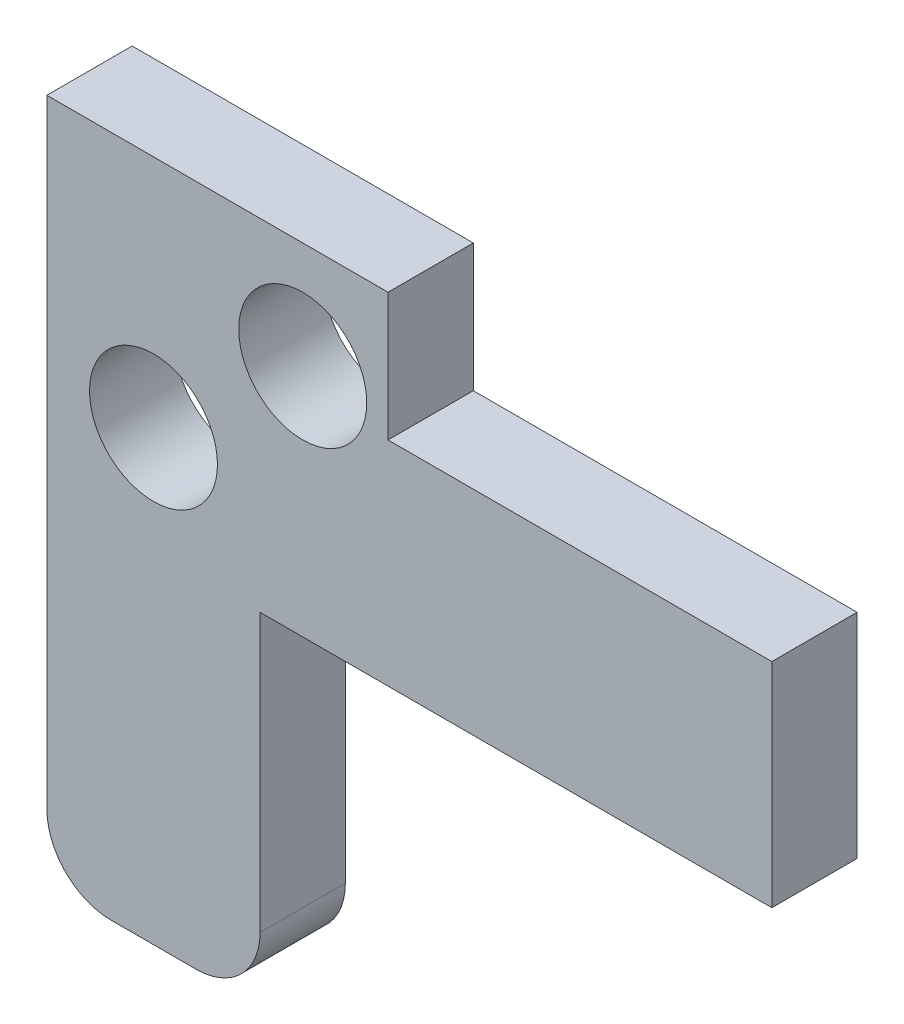
from build123d import *

# Parameters (mm, degrees)
SKETCH_6_W          = 5
SKETCH_6_H          = 21
EXTRUDE_1_DEPTH     = 2
SKETCH_10_W         = 2
SKETCH_10_H         = 5
EXTRUDE_3_DEPTH     = 20
SKETCH_11_W         = 8
SKETCH_11_H         = 5
CUT_EXTRUDE_3_DEPTH = 20
SKETCH_12_R         = 1.5
CUT_EXTRUDE_4_DEPTH = 20
SKETCH_13_W         = 5
SKETCH_13_H         = 2
CUT_EXTRUDE_5_DEPTH = 8
FILLET_1_R          = 1.5
SKETCH_19_W         = 8
SKETCH_19_H         = 2
EXTRUDE_6_DEPTH     = 3
SKETCH_20_R         = 1.5
CUT_EXTRUDE_7_DEPTH = 5


with BuildPart() as part:
    # 草图6 → 凸台-拉伸1 (new body)
    with BuildSketch(Plane.XY):
        with Locations((-2.5, 10.5)):
            Rectangle(SKETCH_6_W, SKETCH_6_H)
    extrude(amount=EXTRUDE_1_DEPTH)

    # 草图10 → 凸台-拉伸3 (add)
    with BuildSketch(Plane(origin=(0, 0, 0), x_dir=(0, 0, -1), z_dir=(1, 0, 0))):
        with Locations((-1, 18.5)):
            Rectangle(SKETCH_10_W, SKETCH_10_H)
    extrude(amount=EXTRUDE_3_DEPTH)

    # 草图11 → 切除-拉伸3 (cut)
    with BuildSketch(Plane(origin=(0, 0, 0), x_dir=(-1, 0, 0), z_dir=(0, 0, -1))):
        with Locations((-16, 18.5)):
            Rectangle(SKETCH_11_W, SKETCH_11_H)
    extrude(amount=-CUT_EXTRUDE_3_DEPTH, mode=Mode.SUBTRACT)

    # 草图12 → 切除-拉伸4 (cut)
    with BuildSketch(Plane(origin=(0, 0, 0), x_dir=(-1, 0, 0), z_dir=(0, 0, -1))):
        with Locations((2.5, 18.5)):
            Circle(SKETCH_12_R)
    extrude(amount=-CUT_EXTRUDE_4_DEPTH, mode=Mode.SUBTRACT)

    # 草图13 → 切除-拉伸5 (cut)
    with BuildSketch(Plane.XZ):
        with Locations((-2.5, 1)):
            Rectangle(SKETCH_13_W, SKETCH_13_H)
    extrude(amount=-CUT_EXTRUDE_5_DEPTH, mode=Mode.SUBTRACT)

    # 圆角1
    fillet_1_edges = [part.edges().sort_by_distance(p)[0] for p in [
        (0, 8, 1),
        (-5, 8, 1),
    ]]
    fillet(fillet_1_edges, radius=FILLET_1_R)

    # 草图19 → 凸台-拉伸6 (add)
    with BuildSketch(Plane(origin=(0, 21, 0), x_dir=(1, 0, 0), z_dir=(0, 1, 0))):
        with Locations((-1, -1)):
            Rectangle(SKETCH_19_W, SKETCH_19_H)
    extrude(amount=EXTRUDE_6_DEPTH)

    # 草图20 → 切除-拉伸7 (cut)
    with BuildSketch(Plane(origin=(0, 0, 0), x_dir=(-1, 0, 0), z_dir=(0, 0, -1))):
        with Locations((-1, 21.5)):
            Circle(SKETCH_20_R)
    extrude(amount=-CUT_EXTRUDE_7_DEPTH, mode=Mode.SUBTRACT)


solid = part.part
